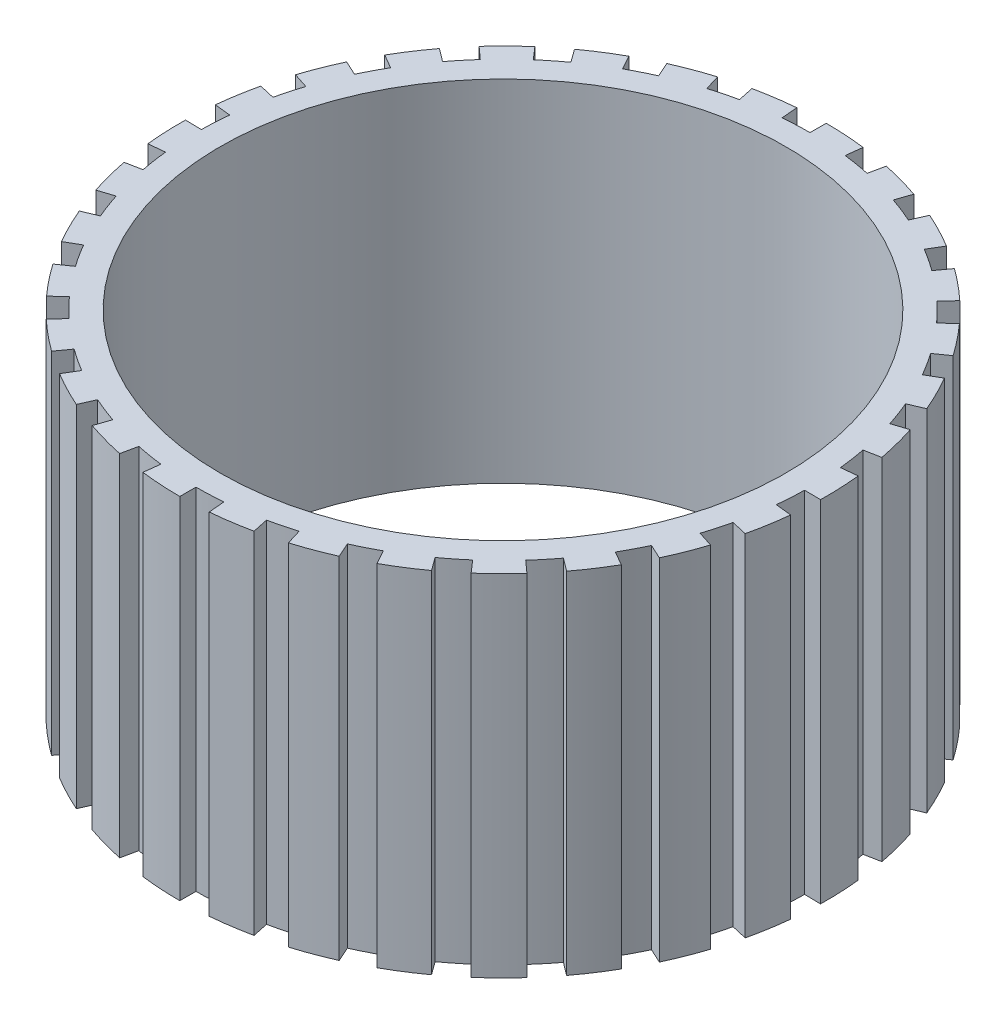
from build123d import *

# Parameters (mm, degrees)
SKETCH1_R           = 52.5
BOSS_EXTRUDE1_DEPTH = 65


with BuildPart() as part:
    # Sketch1 → Boss-Extrude1 (new body)
    with BuildSketch(Plane(origin=(0, 0, 0), x_dir=(1, 0, 0), z_dir=(0, 1, 0))):
        with BuildLine():
            Line((0, 57), (0, 60))
            ThreePointArc((0, 60), (3.662912372, 59.888087905), (7.312160604, 59.552769098))
            Line((7.312160604, 59.552769098), (6.946552574, 56.575130644))
            ThreePointArc((6.946552574, 56.575130644), (9.407713534, 56.218279288), (11.850966377, 55.754413242))
            Line((11.850966377, 55.754413242), (12.474701449, 58.688856044))
            ThreePointArc((12.474701449, 58.688856044), (16.034302565, 57.817827193), (19.534089267, 56.731114536))
            Line((19.534089267, 56.731114536), (18.557384804, 53.894558809))
            ThreePointArc((18.557384804, 53.894558809), (20.890569923, 53.033801375), (23.183988655, 52.072091086))
            Line((23.183988655, 52.072091086), (24.404198585, 54.812727459))
            ThreePointArc((24.404198585, 54.812727459), (27.704916794, 53.220649991), (30.902284495, 51.430038042))
            Line((30.902284495, 51.430038042), (29.35717027, 48.85853614))
            ThreePointArc((29.35717027, 48.85853614), (31.460408163, 47.531491858), (33.503759381, 46.113968679))
            Line((33.503759381, 46.113968679), (35.267115138, 48.541019662))
            ThreePointArc((35.267115138, 48.541019662), (38.164693217, 46.297475003), (40.919901604, 43.881222097))
            Line((40.919901604, 43.881222097), (38.873906524, 41.687160992))
            ThreePointArc((38.873906524, 41.687160992), (40.655275602, 39.951828065), (42.359255052, 38.140444562))
            Line((42.359255052, 38.140444562), (44.588689529, 40.147836382))
            ThreePointArc((44.588689529, 40.147836382), (46.956489411, 37.350878198), (49.149122657, 34.414586181))
            Line((49.149122657, 34.414586181), (46.691666524, 32.693856872))
            ThreePointArc((46.691666524, 32.693856872), (48.073312411, 30.626077676), (49.363448016, 28.5))
            Line((49.363448016, 28.5), (51.961524227, 30))
            ThreePointArc((51.961524227, 30), (53.696061696, 26.771868787), (55.230291207, 23.443867709))
            Line((55.230291207, 23.443867709), (52.468776647, 22.271674324))
            ThreePointArc((52.468776647, 22.271674324), (53.390314787, 19.961820732), (54.210221429, 17.613968679))
            Line((54.210221429, 17.613968679), (57.063390978, 18.541019662))
            ThreePointArc((57.063390978, 18.541019662), (58.088858423, 15.022800243), (58.897631007, 11.448539723))
            Line((58.897631007, 11.448539723), (55.952749457, 10.876112736))
            ThreePointArc((55.952749457, 10.876112736), (56.373904212, 8.425136434), (56.687748036, 5.958122406))
            Line((56.687748036, 5.958122406), (59.671313722, 6.271707796))
            ThreePointArc((59.671313722, 6.271707796), (59.942893295, 2.617163242), (59.990861709, -1.047144386))
            Line((59.990861709, -1.047144386), (56.991318624, -0.994787167))
            ThreePointArc((56.991318624, -0.994787167), (56.89368351, -3.479766753), (56.687748036, -5.958122406))
            Line((56.687748036, -5.958122406), (59.671313722, -6.271707796))
            ThreePointArc((59.671313722, -6.271707796), (59.177136092, -9.902856352), (58.462203887, -13.497063261))
            Line((58.462203887, -13.497063261), (55.539093693, -12.822210098))
            ThreePointArc((55.539093693, -12.822210098), (54.926935833, -15.232587436), (54.210221429, -17.613968679))
            Line((54.210221429, -17.613968679), (57.063390978, -18.541019662))
            ThreePointArc((57.063390978, -18.541019662), (55.825054079, -21.990073603), (54.378467222, -25.357095704))
            Line((54.378467222, -25.357095704), (51.659543861, -24.089240919))
            ThreePointArc((51.659543861, -24.089240919), (50.559617491, -26.319670954), (49.363448016, -28.5))
            Line((49.363448016, -28.5), (51.961524227, -30))
            ThreePointArc((51.961524227, -30), (50.033149324, -33.116219119), (47.918130603, -36.108901389))
            Line((47.918130603, -36.108901389), (45.522224073, -34.30345632))
            ThreePointArc((45.522224073, -34.30345632), (43.982601253, -36.256458556), (42.359255052, -38.140444562))
            Line((42.359255052, -38.140444562), (44.588689529, -40.147836382))
            ThreePointArc((44.588689529, -40.147836382), (42.054555858, -42.795026949), (39.363541739, -45.282574813))
            Line((39.363541739, -45.282574813), (37.395364652, -43.018446073))
            ThreePointArc((37.395364652, -43.018446073), (35.483334288, -44.608664941), (33.503759381, -46.113968679))
            Line((33.503759381, -46.113968679), (35.267115138, -48.541019662))
            ThreePointArc((35.267115138, -48.541019662), (32.237976501, -50.603486749), (29.088577215, -52.477182428))
            Line((29.088577215, -52.477182428), (27.634148354, -49.853323307))
            ThreePointArc((27.634148354, -49.853323307), (25.433275347, -51.011258611), (23.183988655, -52.072091086))
            Line((23.183988655, -52.072091086), (24.404198585, -54.812727459))
            ThreePointArc((24.404198585, -54.812727459), (21.012442876, -56.200331355), (17.542302283, -57.378285358))
            Line((17.542302283, -57.378285358), (16.665187169, -54.50937109))
            ThreePointArc((16.665187169, -54.50937109), (14.271660231, -55.184415502), (11.850966377, -55.754413242))
            Line((11.850966377, -55.754413242), (12.474701449, -58.688856044))
            ThreePointArc((12.474701449, -58.688856044), (8.868564668, -59.340951802), (5.229344565, -59.771681886))
            Line((5.229344565, -59.771681886), (4.967877337, -56.783097791))
            ThreePointArc((4.967877337, -56.783097791), (2.48630508, -56.94574863), (0, -57))
            Line((0, -57), (0, -60))
            ThreePointArc((0, -60), (-3.662912372, -59.888087905), (-7.312160604, -59.552769098))
            Line((-7.312160604, -59.552769098), (-6.946552574, -56.575130644))
            ThreePointArc((-6.946552574, -56.575130644), (-9.407713534, -56.218279288), (-11.850966377, -55.754413242))
            Line((-11.850966377, -55.754413242), (-12.474701449, -58.688856044))
            ThreePointArc((-12.474701449, -58.688856044), (-16.034302565, -57.817827193), (-19.534089267, -56.731114536))
            Line((-19.534089267, -56.731114536), (-18.557384804, -53.894558809))
            ThreePointArc((-18.557384804, -53.894558809), (-20.890569923, -53.033801375), (-23.183988655, -52.072091086))
            Line((-23.183988655, -52.072091086), (-24.404198585, -54.812727459))
            ThreePointArc((-24.404198585, -54.812727459), (-27.704916794, -53.220649991), (-30.902284495, -51.430038042))
            Line((-30.902284495, -51.430038042), (-29.35717027, -48.85853614))
            ThreePointArc((-29.35717027, -48.85853614), (-31.460408163, -47.531491858), (-33.503759381, -46.113968679))
            Line((-33.503759381, -46.113968679), (-35.267115138, -48.541019662))
            ThreePointArc((-35.267115138, -48.541019662), (-38.164693217, -46.297475003), (-40.919901604, -43.881222097))
            Line((-40.919901604, -43.881222097), (-38.873906524, -41.687160992))
            ThreePointArc((-38.873906524, -41.687160992), (-40.655275602, -39.951828065), (-42.359255052, -38.140444562))
            Line((-42.359255052, -38.140444562), (-44.588689529, -40.147836382))
            ThreePointArc((-44.588689529, -40.147836382), (-46.956489411, -37.350878198), (-49.149122657, -34.414586181))
            Line((-49.149122657, -34.414586181), (-46.691666524, -32.693856872))
            ThreePointArc((-46.691666524, -32.693856872), (-48.073312411, -30.626077676), (-49.363448016, -28.5))
            Line((-49.363448016, -28.5), (-51.961524227, -30))
            ThreePointArc((-51.961524227, -30), (-53.696061696, -26.771868787), (-55.230291207, -23.443867709))
            Line((-55.230291207, -23.443867709), (-52.468776647, -22.271674324))
            ThreePointArc((-52.468776647, -22.271674324), (-53.390314787, -19.961820732), (-54.210221429, -17.613968679))
            Line((-54.210221429, -17.613968679), (-57.063390978, -18.541019662))
            ThreePointArc((-57.063390978, -18.541019662), (-58.088858423, -15.022800243), (-58.897631007, -11.448539723))
            Line((-58.897631007, -11.448539723), (-55.952749457, -10.876112736))
            ThreePointArc((-55.952749457, -10.876112736), (-56.373904212, -8.425136434), (-56.687748036, -5.958122406))
            Line((-56.687748036, -5.958122406), (-59.671313722, -6.271707796))
            ThreePointArc((-59.671313722, -6.271707796), (-59.942893295, -2.617163242), (-59.990861709, 1.047144386))
            Line((-59.990861709, 1.047144386), (-56.991318624, 0.994787167))
            ThreePointArc((-56.991318624, 0.994787167), (-56.89368351, 3.479766753), (-56.687748036, 5.958122406))
            Line((-56.687748036, 5.958122406), (-59.671313722, 6.271707796))
            ThreePointArc((-59.671313722, 6.271707796), (-59.177136092, 9.902856352), (-58.462203887, 13.497063261))
            Line((-58.462203887, 13.497063261), (-55.539093693, 12.822210098))
            ThreePointArc((-55.539093693, 12.822210098), (-54.926935833, 15.232587436), (-54.210221429, 17.613968679))
            Line((-54.210221429, 17.613968679), (-57.063390978, 18.541019662))
            ThreePointArc((-57.063390978, 18.541019662), (-55.825054079, 21.990073603), (-54.378467222, 25.357095704))
            Line((-54.378467222, 25.357095704), (-51.659543861, 24.089240919))
            ThreePointArc((-51.659543861, 24.089240919), (-50.559617491, 26.319670954), (-49.363448016, 28.5))
            Line((-49.363448016, 28.5), (-51.961524227, 30))
            ThreePointArc((-51.961524227, 30), (-50.033149324, 33.116219119), (-47.918130603, 36.108901389))
            Line((-47.918130603, 36.108901389), (-45.522224073, 34.30345632))
            ThreePointArc((-45.522224073, 34.30345632), (-43.982601253, 36.256458556), (-42.359255052, 38.140444562))
            Line((-42.359255052, 38.140444562), (-44.588689529, 40.147836382))
            ThreePointArc((-44.588689529, 40.147836382), (-42.054555858, 42.795026949), (-39.363541739, 45.282574813))
            Line((-39.363541739, 45.282574813), (-37.395364652, 43.018446073))
            ThreePointArc((-37.395364652, 43.018446073), (-35.483334288, 44.608664941), (-33.503759381, 46.113968679))
            Line((-33.503759381, 46.113968679), (-35.267115138, 48.541019662))
            ThreePointArc((-35.267115138, 48.541019662), (-32.237976501, 50.603486749), (-29.088577215, 52.477182428))
            Line((-29.088577215, 52.477182428), (-27.634148354, 49.853323307))
            ThreePointArc((-27.634148354, 49.853323307), (-25.433275347, 51.011258611), (-23.183988655, 52.072091086))
            Line((-23.183988655, 52.072091086), (-24.404198585, 54.812727459))
            ThreePointArc((-24.404198585, 54.812727459), (-21.012442876, 56.200331355), (-17.542302283, 57.378285358))
            Line((-17.542302283, 57.378285358), (-16.665187169, 54.50937109))
            ThreePointArc((-16.665187169, 54.50937109), (-14.271660231, 55.184415502), (-11.850966377, 55.754413242))
            Line((-11.850966377, 55.754413242), (-12.474701449, 58.688856044))
            ThreePointArc((-12.474701449, 58.688856044), (-8.868564668, 59.340951802), (-5.229344565, 59.771681886))
            Line((-5.229344565, 59.771681886), (-4.967877337, 56.783097791))
            ThreePointArc((-4.967877337, 56.783097791), (-2.48630508, 56.94574863), (0, 57))
        make_face()
        Circle(SKETCH1_R, mode=Mode.SUBTRACT)
    extrude(amount=BOSS_EXTRUDE1_DEPTH)


solid = part.part
